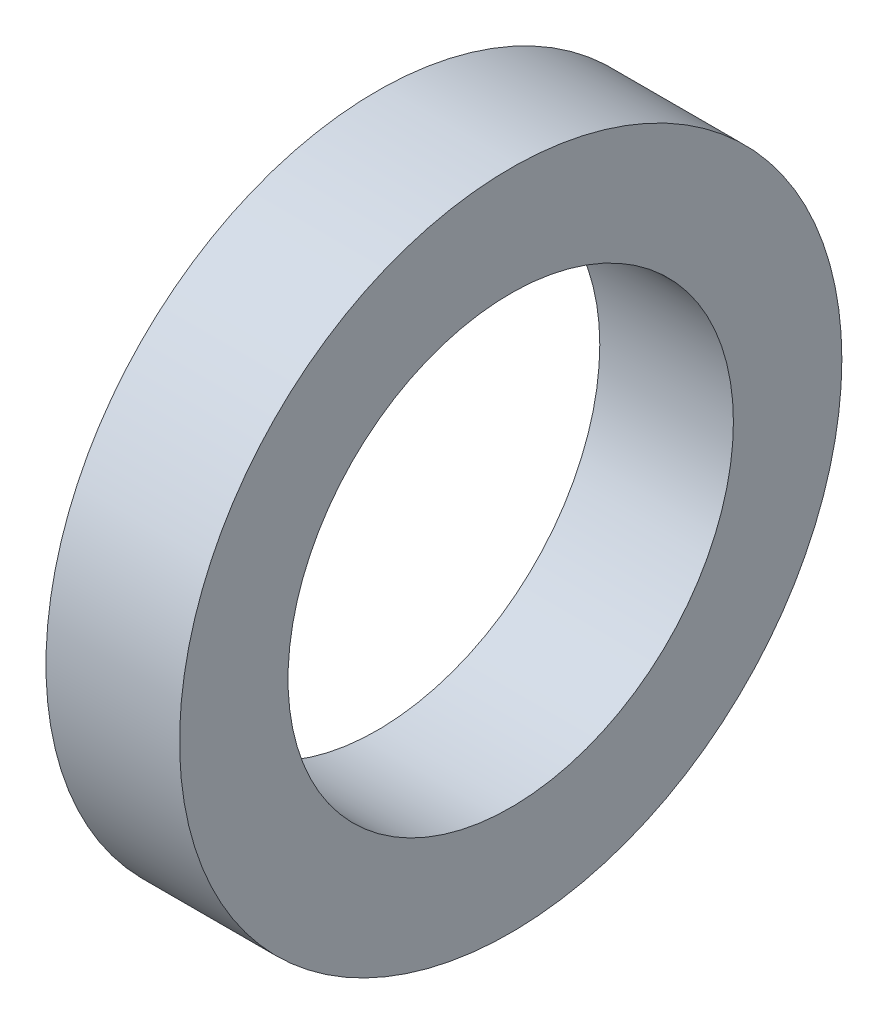
from build123d import *

# Parameters (mm, degrees)
SKETCH1_R           = 47.21225
SKETCH1_R_2         = 31.75
BOSS_EXTRUDE1_DEPTH = 9.525


with BuildPart() as part:
    # Sketch1 → Boss-Extrude1 (new body, symmetric)
    with BuildSketch(Plane(origin=(0, 0, 0), x_dir=(0, 0, -1), z_dir=(1, 0, 0))):
        Circle(SKETCH1_R)
        Circle(SKETCH1_R_2, mode=Mode.SUBTRACT)
    extrude(amount=BOSS_EXTRUDE1_DEPTH, both=True)


solid = part.part
